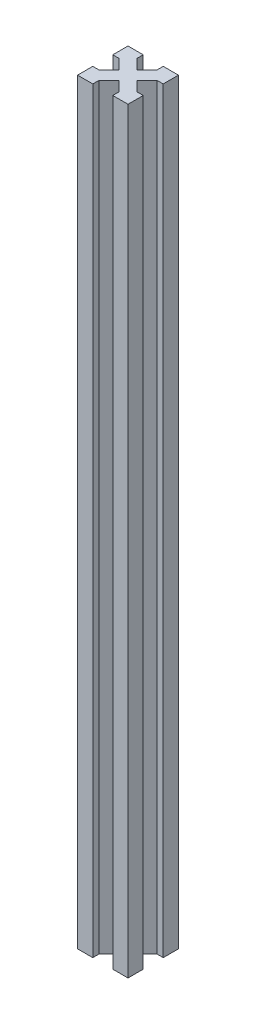
from build123d import *

# Parameters (mm, degrees)
BOSS_EXTRU_1_DEPTH = 300


with BuildPart() as part:
    # Esquisse1 → Boss.-Extru.1 (new body)
    with BuildSketch(Plane(origin=(0, 0, 0), x_dir=(1, 0, 0), z_dir=(0, 1, 0))):
        Polygon((-3.535533906, 0), (-6.035533906, 2.5), (-6.035533906, 0), align=None)
        Polygon((0, 3.535533906), (-2.5, 6.035533906), (-2.5, 2.5), (-6.035533906, 2.5), (-3.535533906, 0), (0, 0), align=None)
        Polygon((0, 6.035533906), (-2.5, 6.035533906), (0, 3.535533906), align=None)
        Polygon((-2.5, 2.5), (-2.5, 6.035533906), (-6.464466094, 10), (-10, 6.464466094), (-6.035533906, 2.5), align=None)
        Polygon((-13.964466094, 0), (-13.964466094, 2.5), (-16.464466094, 0), align=None)
        Polygon((-17.5, 2.5), (-17.5, 6.035533906), (-20, 3.535533906), (-20, 0), (-16.464466094, 0), (-13.964466094, 2.5), align=None)
        Polygon((-20, 3.535533906), (-17.5, 6.035533906), (-20, 6.035533906), align=None)
        Polygon((-10, 6.464466094), (-13.535533906, 10), (-17.5, 6.035533906), (-17.5, 2.5), (-13.964466094, 2.5), align=None)
        Polygon((-6.464466094, 10), (-10, 13.535533906), (-13.535533906, 10), (-10, 6.464466094), align=None)
        Polygon((-2.5, 13.964466094), (-2.5, 17.5), (-6.035533906, 17.5), (-10, 13.535533906), (-6.464466094, 10), align=None)
        Polygon((-6.035533906, 17.5), (-2.5, 17.5), (-2.5, 13.964466094), (0, 16.464466094), (0, 20), (-3.535533906, 20), align=None)
        Polygon((0, 16.464466094), (-2.5, 13.964466094), (0, 13.964466094), align=None)
        Polygon((-6.035533906, 20), (-6.035533906, 17.5), (-3.535533906, 20), align=None)
        Polygon((-16.464466094, 20), (-13.964466094, 17.5), (-13.964466094, 20), align=None)
        Polygon((-17.5, 17.5), (-13.964466094, 17.5), (-16.464466094, 20), (-20, 20), (-20, 16.464466094), (-17.5, 13.964466094), align=None)
        Polygon((-20, 13.964466094), (-17.5, 13.964466094), (-20, 16.464466094), align=None)
        Polygon((-10, 13.535533906), (-13.964466094, 17.5), (-17.5, 17.5), (-17.5, 13.964466094), (-13.535533906, 10), align=None)
    extrude(amount=BOSS_EXTRU_1_DEPTH)


solid = part.part
